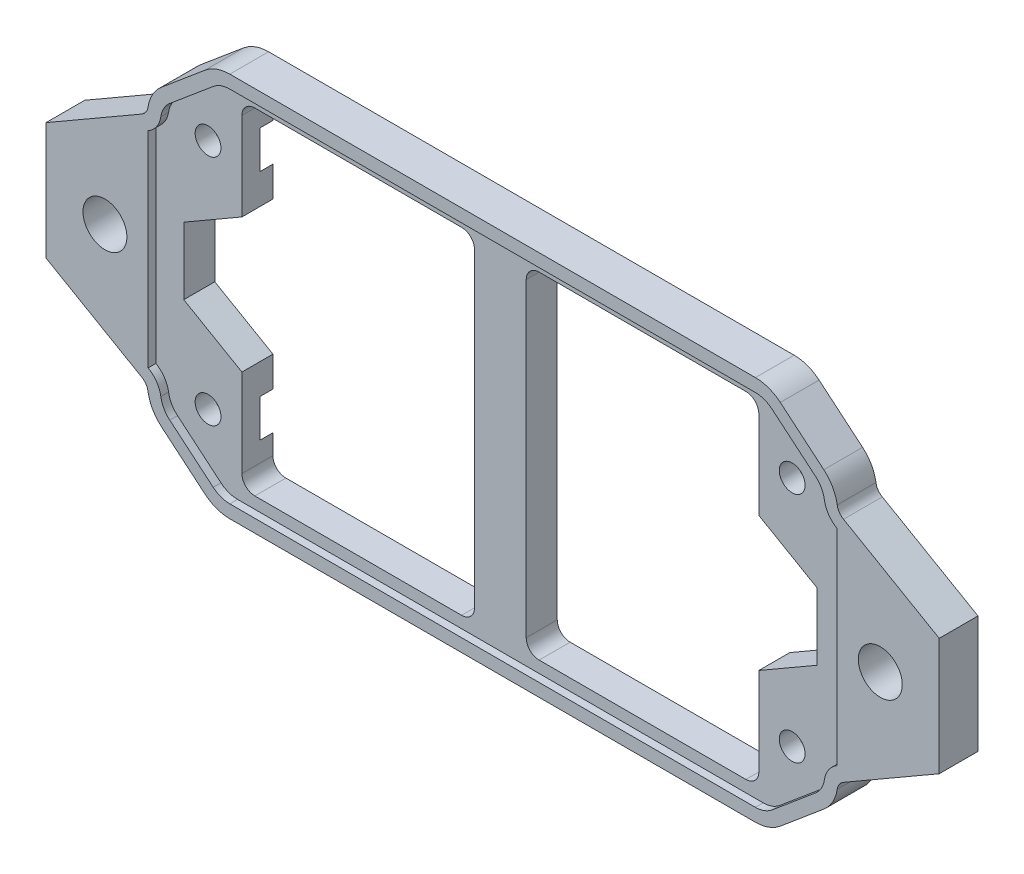
from build123d import *

# Parameters (mm, degrees)
EXTRUDE_2_DEPTH      = 3
CUT_EXTRUDE_1_DEPTH  = 0.6
SKETCH_6_W           = 18
SKETCH_6_H           = 26
CUT_EXTRUDE_4_DEPTH  = 3.4
FILLET_1_R           = 1
CUT_EXTRUDE_6_DEPTH  = 3.4
FILLET_2_R           = 1
SKETCH_22_R          = 1.7
CUT_EXTRUDE_18_DEPTH = 4
SKETCH_23_R          = 3
CUT_EXTRUDE_19_DEPTH = 1


with BuildPart() as part:
    # 草图1 → 凸台-拉伸2 (new body)
    with BuildSketch(Plane.XY):
        with BuildLine():
            ThreePointArc((-4.008613189, 3.630478791), (-4.334307099, 3.328571786), (-4.497154053, 2.91540689))
            ThreePointArc((-4.497154053, 2.91540689), (-4.847622487, 1.898244021), (-5.534413817, 1.070134068))
            Line((-5.534413817, 1.070134068), (-8.898384051, -1.752572115))
            ThreePointArc((-8.898384051, -1.752572115), (-9.80068645, -2.273516648), (-10.82674688, -2.454438786))
            Line((-10.82674688, -2.454438786), (-51.498806412, -2.454438786))
            ThreePointArc((-51.498806412, -2.454438786), (-52.524866842, -2.273516648), (-53.427169241, -1.752572115))
            Line((-53.427169241, -1.752572115), (-56.791139475, 1.070134068))
            ThreePointArc((-56.791139475, 1.070134068), (-57.477930804, 1.898244021), (-57.828399238, 2.91540689))
            ThreePointArc((-57.828399238, 2.91540689), (-57.991246193, 3.328571786), (-58.316940102, 3.630478791))
            Line((-58.316940102, 3.630478791), (-65.723943689, 7.906914306))
            Line((-65.723943689, 7.906914306), (-65.723943689, 16.984208123))
            Line((-65.723943689, 16.984208123), (-58.316940102, 21.260643637))
            ThreePointArc((-58.316940102, 21.260643637), (-57.991246193, 21.562550642), (-57.828399238, 21.975715539))
            ThreePointArc((-57.828399238, 21.975715539), (-57.477930804, 22.992878408), (-56.791139475, 23.820988361))
            Line((-56.791139475, 23.820988361), (-53.427169241, 26.643694544))
            ThreePointArc((-53.427169241, 26.643694544), (-52.524866842, 27.164639077), (-51.498806412, 27.345561214))
            Line((-51.498806412, 27.345561214), (-10.82674688, 27.345561214))
            ThreePointArc((-10.82674688, 27.345561214), (-9.80068645, 27.164639077), (-8.898384051, 26.643694544))
            Line((-8.898384051, 26.643694544), (-5.534413817, 23.820988361))
            ThreePointArc((-5.534413817, 23.820988361), (-4.847622487, 22.992878408), (-4.497154053, 21.975715539))
            ThreePointArc((-4.497154053, 21.975715539), (-4.334307099, 21.562550642), (-4.008613189, 21.260643637))
            Line((-4.008613189, 21.260643637), (3.398390397, 16.984208123))
            Line((3.398390397, 16.984208123), (3.398390397, 7.906914306))
            Line((3.398390397, 7.906914306), (-4.008613189, 3.630478791))
        make_face()
        with BuildLine():
            ThreePointArc((-51.498806412, 26.345561214), (-52.182846698, 26.224946456), (-52.784381631, 25.8776501))
            Line((-52.784381631, 25.8776501), (-56.148351865, 23.054943918))
            ThreePointArc((-56.148351865, 23.054943918), (-56.67539222, 22.368091555), (-56.862776646, 21.522855031))
            Line((-56.862776646, 21.522855031), (-56.862776646, 3.368267397))
            ThreePointArc((-56.862776646, 3.368267397), (-56.67539222, 2.523030874), (-56.148351865, 1.836178511))
            Line((-56.148351865, 1.836178511), (-52.784381631, -0.986527672))
            ThreePointArc((-52.784381631, -0.986527672), (-52.182846698, -1.333824027), (-51.498806412, -1.454438786))
            Line((-51.498806412, -1.454438786), (-10.82674688, -1.454438786))
            ThreePointArc((-10.82674688, -1.454438786), (-10.142706593, -1.333824027), (-9.541171661, -0.986527672))
            Line((-9.541171661, -0.986527672), (-6.177201426, 1.836178511))
            ThreePointArc((-6.177201426, 1.836178511), (-5.650161072, 2.523030874), (-5.462776646, 3.368267397))
            Line((-5.462776646, 3.368267397), (-5.462776646, 21.522855031))
            ThreePointArc((-5.462776646, 21.522855031), (-5.650161072, 22.368091555), (-6.177201426, 23.054943918))
            Line((-6.177201426, 23.054943918), (-9.541171661, 25.8776501))
            ThreePointArc((-9.541171661, 25.8776501), (-10.142706593, 26.224946456), (-10.82674688, 26.345561214))
            Line((-10.82674688, 26.345561214), (-51.498806412, 26.345561214))
        make_face(mode=Mode.SUBTRACT)
        with BuildLine():
            Line((-10.82674688, 26.345561214), (-51.498806412, 26.345561214))
            ThreePointArc((-51.498806412, 26.345561214), (-52.182846698, 26.224946456), (-52.784381631, 25.8776501))
            Line((-52.784381631, 25.8776501), (-56.148351865, 23.054943918))
            ThreePointArc((-56.148351865, 23.054943918), (-56.67539222, 22.368091555), (-56.862776646, 21.522855031))
            Line((-56.862776646, 21.522855031), (-56.862776646, 3.368267397))
            ThreePointArc((-56.862776646, 3.368267397), (-56.67539222, 2.523030874), (-56.148351865, 1.836178511))
            Line((-56.148351865, 1.836178511), (-52.784381631, -0.986527672))
            ThreePointArc((-52.784381631, -0.986527672), (-52.182846698, -1.333824027), (-51.498806412, -1.454438786))
            Line((-51.498806412, -1.454438786), (-10.82674688, -1.454438786))
            ThreePointArc((-10.82674688, -1.454438786), (-10.142706593, -1.333824027), (-9.541171661, -0.986527672))
            Line((-9.541171661, -0.986527672), (-6.177201426, 1.836178511))
            ThreePointArc((-6.177201426, 1.836178511), (-5.650161072, 2.523030874), (-5.462776646, 3.368267397))
            Line((-5.462776646, 3.368267397), (-5.462776646, 21.522855031))
            ThreePointArc((-5.462776646, 21.522855031), (-5.650161072, 22.368091555), (-6.177201426, 23.054943918))
            Line((-6.177201426, 23.054943918), (-9.541171661, 25.8776501))
            ThreePointArc((-9.541171661, 25.8776501), (-10.142706593, 26.224946456), (-10.82674688, 26.345561214))
        make_face()
        with BuildLine():
            ThreePointArc((-53.78228524, 2.445561214), (-52.78228524, 3.445561214), (-53.78228524, 4.445561214))
            ThreePointArc((-53.78228524, 4.445561214), (-54.78228524, 3.445561214), (-53.78228524, 2.445561214))
        make_face(mode=Mode.SUBTRACT)
        with BuildLine():
            ThreePointArc((-53.78228524, 20.445561214), (-52.78228524, 21.445561214), (-53.78228524, 22.445561214))
            ThreePointArc((-53.78228524, 22.445561214), (-54.78228524, 21.445561214), (-53.78228524, 20.445561214))
        make_face(mode=Mode.SUBTRACT)
        with BuildLine():
            ThreePointArc((-8.58228524, 2.445561214), (-7.58228524, 3.445561214), (-8.58228524, 4.445561214))
            ThreePointArc((-8.58228524, 4.445561214), (-9.58228524, 3.445561214), (-8.58228524, 2.445561214))
        make_face(mode=Mode.SUBTRACT)
        with BuildLine():
            ThreePointArc((-8.58228524, 20.445561214), (-7.58228524, 21.445561214), (-8.58228524, 22.445561214))
            ThreePointArc((-8.58228524, 22.445561214), (-9.58228524, 21.445561214), (-8.58228524, 20.445561214))
        make_face(mode=Mode.SUBTRACT)
    extrude(amount=EXTRUDE_2_DEPTH)

    # 草图4 → 切除-拉伸1 (cut)
    with BuildSketch(Plane.XY.offset(3)):
        with BuildLine():
            Line((-56.148351865, 1.836178511), (-52.784381631, -0.986527672))
            ThreePointArc((-52.784381631, -0.986527672), (-52.182846698, -1.333824027), (-51.498806412, -1.454438786))
            Line((-51.498806412, -1.454438786), (-10.82674688, -1.454438786))
            ThreePointArc((-10.82674688, -1.454438786), (-10.142706593, -1.333824027), (-9.541171661, -0.986527672))
            Line((-9.541171661, -0.986527672), (-6.177201426, 1.836178511))
            ThreePointArc((-6.177201426, 1.836178511), (-5.71934054, 2.388251813), (-5.485694918, 3.066360392))
            ThreePointArc((-5.485694918, 3.066360392), (-5.160001008, 3.892690185), (-4.508613189, 4.496504195))
            Line((-4.508613189, 4.496504195), (-4.508613189, 20.394618234))
            ThreePointArc((-4.508613189, 20.394618234), (-5.160001008, 20.998432243), (-5.485694918, 21.824762036))
            ThreePointArc((-5.485694918, 21.824762036), (-5.71934054, 22.502870615), (-6.177201426, 23.054943918))
            Line((-6.177201426, 23.054943918), (-9.541171661, 25.8776501))
            ThreePointArc((-9.541171661, 25.8776501), (-10.142706593, 26.224946456), (-10.82674688, 26.345561214))
            Line((-10.82674688, 26.345561214), (-51.498806412, 26.345561214))
            ThreePointArc((-51.498806412, 26.345561214), (-52.182846698, 26.224946456), (-52.784381631, 25.8776501))
            Line((-52.784381631, 25.8776501), (-56.148351865, 23.054943918))
            ThreePointArc((-56.148351865, 23.054943918), (-56.606212752, 22.502870615), (-56.839858374, 21.824762036))
            ThreePointArc((-56.839858374, 21.824762036), (-57.165552284, 20.998432243), (-57.816940102, 20.394618234))
            Line((-57.816940102, 20.394618234), (-57.816940102, 4.496504195))
            ThreePointArc((-57.816940102, 4.496504195), (-57.165552284, 3.892690185), (-56.839858374, 3.066360392))
            ThreePointArc((-56.839858374, 3.066360392), (-56.606212752, 2.388251813), (-56.148351865, 1.836178511))
        make_face()
    extrude(amount=-CUT_EXTRUDE_1_DEPTH, mode=Mode.SUBTRACT)

    # 草图6 → 切除-拉伸4 (cut, through all)
    with BuildSketch(Plane.XY.offset(2.4)):
        with Locations((-20.162776646, 12.445561214)):
            Rectangle(SKETCH_6_W, SKETCH_6_H)
        with Locations((-42.162776646, 12.445561214)):
            Rectangle(SKETCH_6_W, SKETCH_6_H)
    extrude(amount=-CUT_EXTRUDE_4_DEPTH, mode=Mode.SUBTRACT)

    # 圆角1
    fillet_1_edges = [part.edges().sort_by_distance(p)[0] for p in [
        (-29.162776646, -0.554438786, 1.2),
        (-29.162776646, 25.445561214, 1.2),
        (-33.162776646, 25.445561214, 1.2),
        (-33.162776646, -0.554438786, 1.2),
    ]]
    fillet(fillet_1_edges, radius=FILLET_1_R)

    # 草图10 → 切除-拉伸6 (cut, through all)
    with BuildSketch(Plane.XY.offset(2.4)):
        Polygon((-11.162776646, 7.249408791), (-11.162776646, 17.641713637), (-6.662776646, 15.043637426), (-6.662776646, 9.847485003), align=None)
        Polygon((-51.162776646, 7.249408791), (-51.162776646, 17.641713637), (-55.662776646, 15.043637426), (-55.662776646, 9.847485003), align=None)
    extrude(amount=-CUT_EXTRUDE_6_DEPTH, mode=Mode.SUBTRACT)

    # 圆角2
    fillet_2_edges = [part.edges().sort_by_distance(p)[0] for p in [
        (-11.162776646, 25.445561214, 1.2),
        (-11.162776646, -0.554438786, 1.2),
        (-51.162776646, -0.554438786, 1.2),
        (-51.162776646, 25.445561214, 1.2),
    ]]
    fillet(fillet_2_edges, radius=FILLET_2_R)

    # 草图22 → 切除-拉伸18 (cut, through all)
    with BuildSketch(Plane.XY.offset(3)):
        with Locations((-1.162776646, 12.445561214)):
            Circle(SKETCH_22_R)
        with Locations((-61.162776646, 12.445561214)):
            Circle(SKETCH_22_R)
    extrude(amount=-CUT_EXTRUDE_18_DEPTH, mode=Mode.SUBTRACT)

    # 草图23 → 切除-拉伸19 (cut)
    with BuildSketch(Plane(origin=(0, 0, 0), x_dir=(-1, 0, 0), z_dir=(0, 0, -1))):
        with Locations((53.78228524, 3.445561214)):
            Circle(SKETCH_23_R)
        with Locations((53.78228524, 21.445561214)):
            Circle(SKETCH_23_R)
        with Locations((8.58228524, 21.445561214)):
            Circle(SKETCH_23_R)
        with Locations((8.58228524, 3.445561214)):
            Circle(SKETCH_23_R)
    extrude(amount=-CUT_EXTRUDE_19_DEPTH, mode=Mode.SUBTRACT)


solid = part.part
